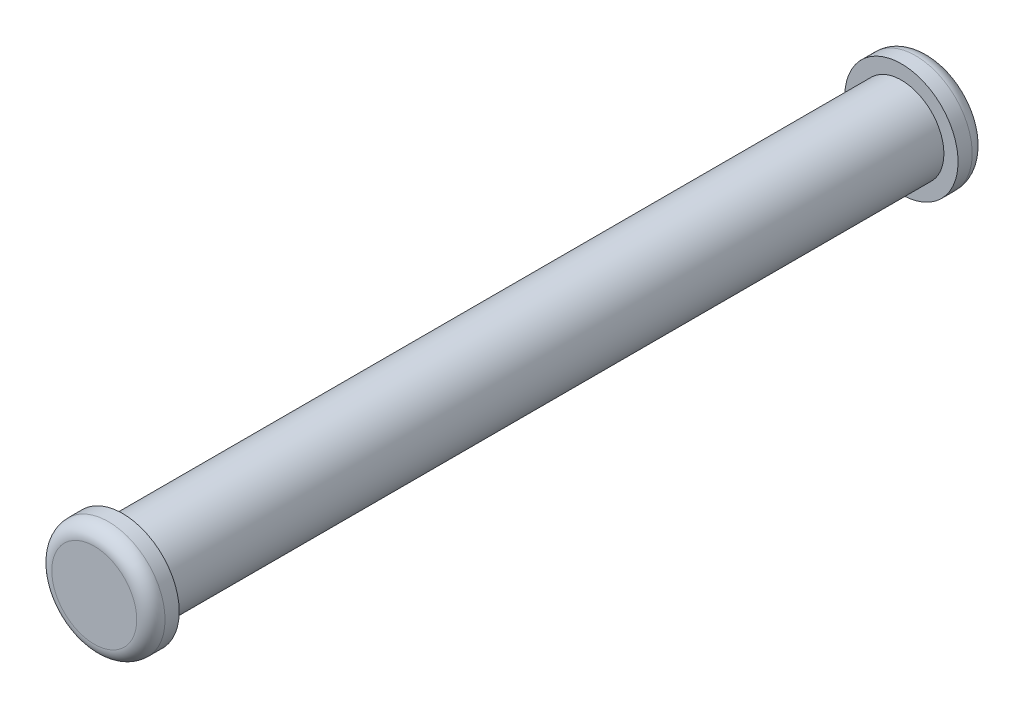
from build123d import *

# Parameters (mm, degrees)
SKETCH1_R           = 1.5
BOSS_EXTRUDE1_DEPTH = 27.5
SKETCH2_R           = 2
BOSS_EXTRUDE2_DEPTH = 1
SKETCH3_R           = 2
BOSS_EXTRUDE3_DEPTH = 1
FILLET1_R           = 0.5


with BuildPart() as part:
    # Sketch1 → Boss-Extrude1 (new body)
    with BuildSketch(Plane.XY):
        Circle(SKETCH1_R)
    extrude(amount=BOSS_EXTRUDE1_DEPTH)

    # Sketch2 → Boss-Extrude2 (add)
    with BuildSketch(Plane(origin=(0, 0, 0), x_dir=(-1, 0, 0), z_dir=(0, 0, -1))):
        Circle(SKETCH2_R)
    extrude(amount=BOSS_EXTRUDE2_DEPTH)

    # Sketch3 → Boss-Extrude3 (add)
    with BuildSketch(Plane.XY.offset(27.5)):
        Circle(SKETCH3_R)
    extrude(amount=BOSS_EXTRUDE3_DEPTH)

    # Fillet1
    fillet1_edges = [part.edges().sort_by_distance(p)[0] for p in [
        (-2, 0, 28.5),
        (2, 0, -1),
    ]]
    fillet(fillet1_edges, radius=FILLET1_R)


solid = part.part
